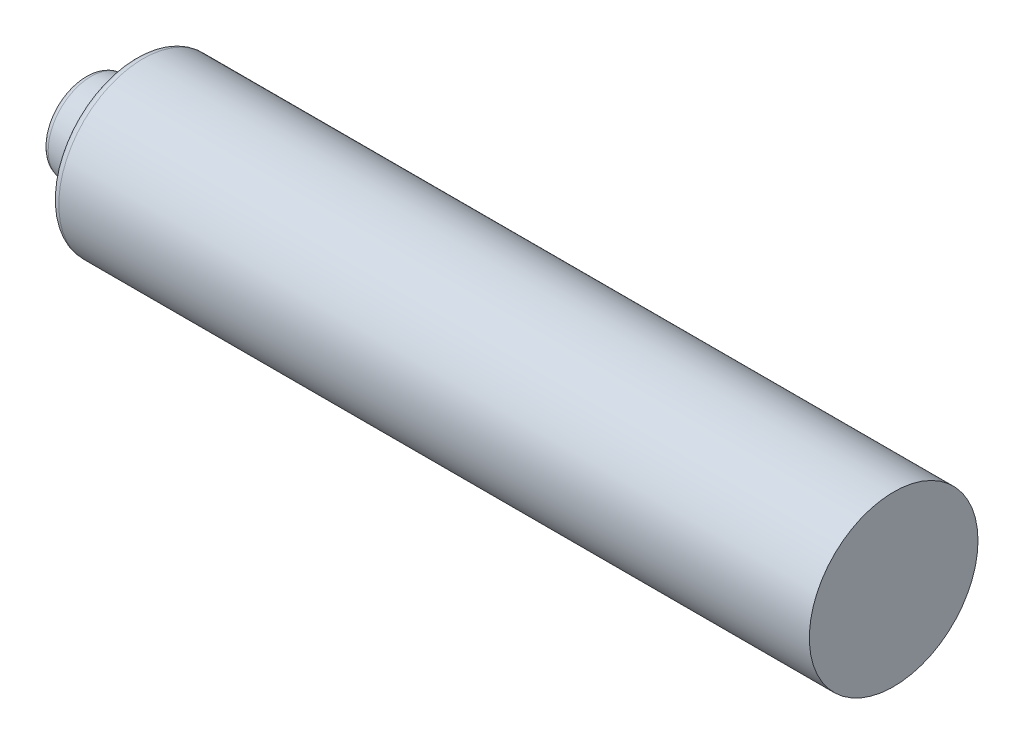
from build123d import *

# Parameters (mm, degrees)
SKETCH1_R           = 5
BOSS_EXTRUDE1_DEPTH = 45
SKETCH2_R           = 3
BOSS_EXTRUDE2_DEPTH = 3
BOSS_EXTRUDE2_TAPER = 10
FILLET1_R           = 0.5


with BuildPart() as part:
    # Sketch1 → Boss-Extrude1 (new body)
    with BuildSketch(Plane(origin=(0, 0, 0), x_dir=(0, 0, -1), z_dir=(1, 0, 0))):
        Circle(SKETCH1_R)
    extrude(amount=BOSS_EXTRUDE1_DEPTH)

    # Sketch2 → Boss-Extrude2 (add)
    with BuildSketch(Plane.ZY):
        Circle(SKETCH2_R)
    extrude(amount=BOSS_EXTRUDE2_DEPTH, taper=BOSS_EXTRUDE2_TAPER)

    # Fillet1
    fillet1_edges = [part.edges().sort_by_distance(p)[0] for p in [
        (0, 0, 5),
        (-3, 0, -2.471019058),
    ]]
    fillet(fillet1_edges, radius=FILLET1_R)


solid = part.part
